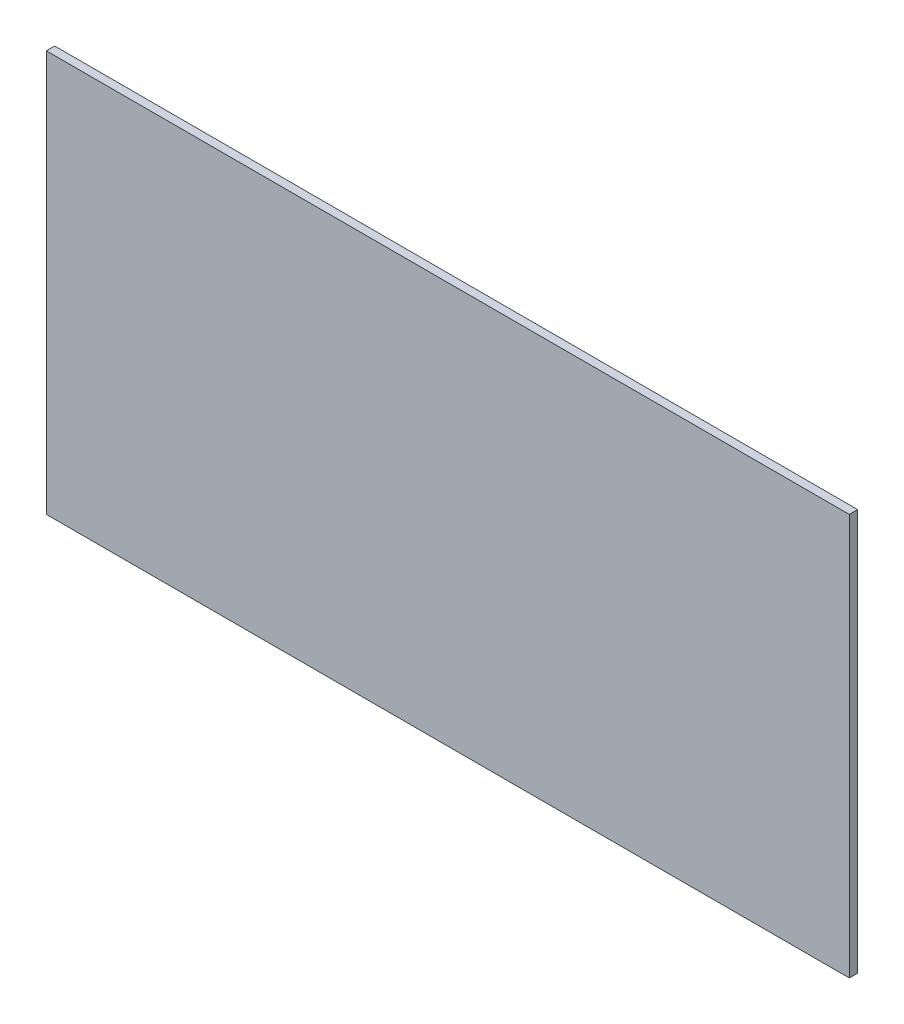
from build123d import *

# Parameters (mm, degrees)
SKETCH1_W           = 609.6
SKETCH1_H           = 304.8
BOSS_EXTRUDE1_DEPTH = 6.35


with BuildPart() as part:
    # Sketch1 → Boss-Extrude1 (new body)
    with BuildSketch(Plane.XY):
        Rectangle(SKETCH1_W, SKETCH1_H)
    extrude(amount=BOSS_EXTRUDE1_DEPTH)


solid = part.part
